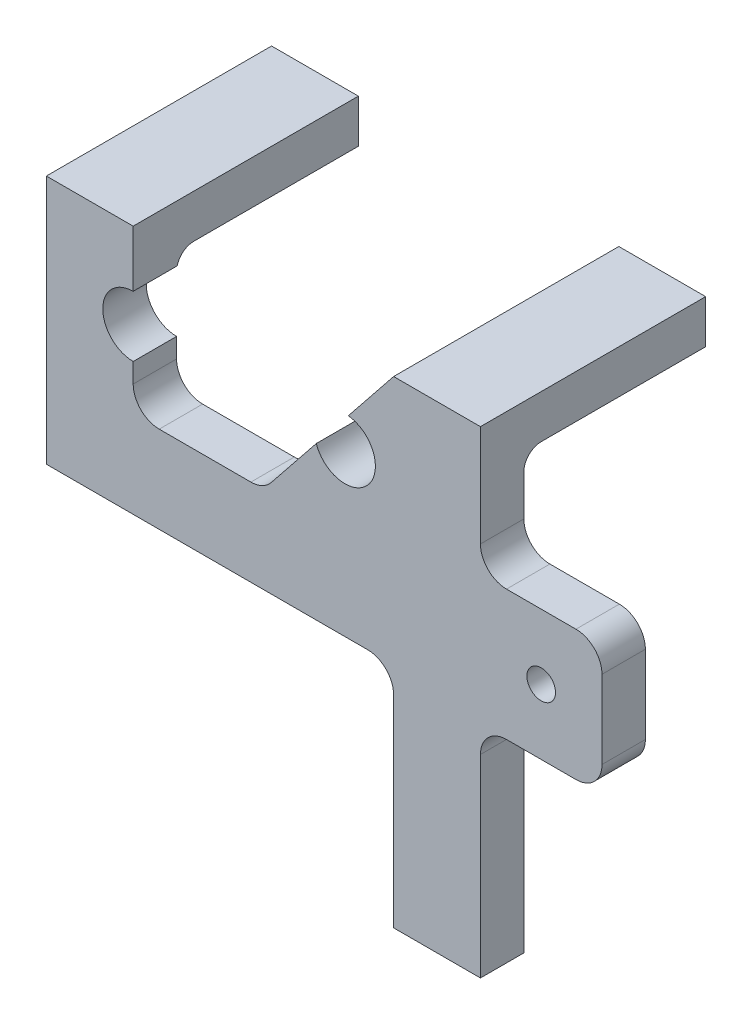
from build123d import *

# Parameters (mm, degrees)
BOSS_EXTRUDE1_DEPTH = 6.35
SKETCH2_W           = 12.7
SKETCH2_H           = 6.35
BOSS_EXTRUDE3_DEPTH = 32.9438
FILLET1_R           = 2.54
SKETCH3_W           = 17.78
SKETCH3_H           = 19.05
SKETCH3_R           = 2.0955
BOSS_EXTRUDE4_DEPTH = 6.35
FILLET2_R           = 3.81


with BuildPart() as part:
    # Sketch1 → Boss-Extrude1 (new body)
    with BuildSketch(Plane.XY):
        with BuildLine():
            Line((0, 0), (0, 69.85))
            Line((0, 69.85), (-12.7, 69.85))
            Line((-12.7, 69.85), (-19.325374009, 61.568282488))
            ThreePointArc((-19.325374009, 61.568282488), (-16.341038142, 54.373230514), (-24.015699161, 55.705376048))
            Line((-24.015699161, 55.705376048), (-31.75, 46.0375))
            Line((-31.75, 46.0375), (-50.8, 46.0375))
            Line((-50.8, 46.0375), (-50.8, 52.705))
            ThreePointArc((-50.8, 52.705), (-55.245, 57.15), (-50.8, 61.595))
            Line((-50.8, 61.595), (-50.8, 69.85))
            Line((-50.8, 69.85), (-63.5, 69.85))
            Line((-63.5, 69.85), (-63.5, 33.3375))
            Line((-63.5, 33.3375), (-12.7, 33.3375))
            Line((-12.7, 33.3375), (-12.7, 0))
            Line((-12.7, 0), (0, 0))
        make_face()
    extrude(amount=BOSS_EXTRUDE1_DEPTH)

    # Sketch2 → Boss-Extrude3 (add)
    with BuildSketch(Plane(origin=(0, 0, 6.35), x_dir=(-1, 0, 0), z_dir=(0, 0, -1))):
        with Locations((6.35, 66.675)):
            Rectangle(SKETCH2_W, SKETCH2_H)
        with Locations((57.15, 66.675)):
            Rectangle(SKETCH2_W, SKETCH2_H)
    extrude(amount=BOSS_EXTRUDE3_DEPTH)

    # Fillet1
    fillet1_edges = [part.edges().sort_by_distance(p)[0] for p in [
        (-57.15, 63.5, 0),
        (-6.35, 63.5, 0),
        (-12.7, 66.675, 0),
    ]]
    fillet(fillet1_edges, radius=FILLET1_R)

    # Sketch3 → Boss-Extrude4 (add)
    with BuildSketch(Plane.XY.offset(6.35)):
        with Locations((8.89, 41.65092)):
            Rectangle(SKETCH3_W, SKETCH3_H)
        with Locations((8.89, 41.65092)):
            Circle(SKETCH3_R, mode=Mode.SUBTRACT)
    extrude(amount=-BOSS_EXTRUDE4_DEPTH)

    # Fillet2
    fillet2_edges = [part.edges().sort_by_distance(p)[0] for p in [
        (17.78, 32.12592, 3.175),
        (17.78, 51.17592, 3.175),
        (0, 51.17592, 3.175),
        (0, 32.12592, 3.175),
        (-12.7, 33.3375, 3.175),
        (-50.8, 46.0375, 3.175),
        (-31.75, 46.0375, 3.175),
    ]]
    fillet(fillet2_edges, radius=FILLET2_R)


solid = part.part
